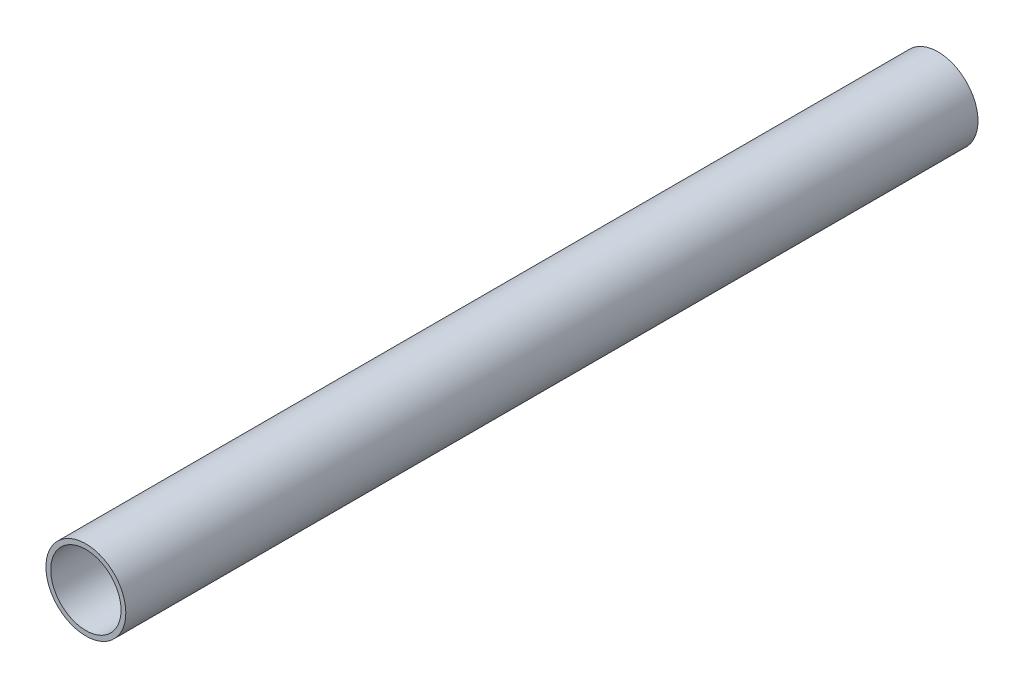
from build123d import *

# Parameters (mm, degrees)
SKETCH1_R           = 9.525
SKETCH1_R_2         = 8.382
BOSS_EXTRUDE1_DEPTH = 203.2


with BuildPart() as part:
    # Sketch1 → Boss-Extrude1 (new body)
    with BuildSketch(Plane.XY):
        Circle(SKETCH1_R)
        Circle(SKETCH1_R_2, mode=Mode.SUBTRACT)
    extrude(amount=BOSS_EXTRUDE1_DEPTH)


solid = part.part
